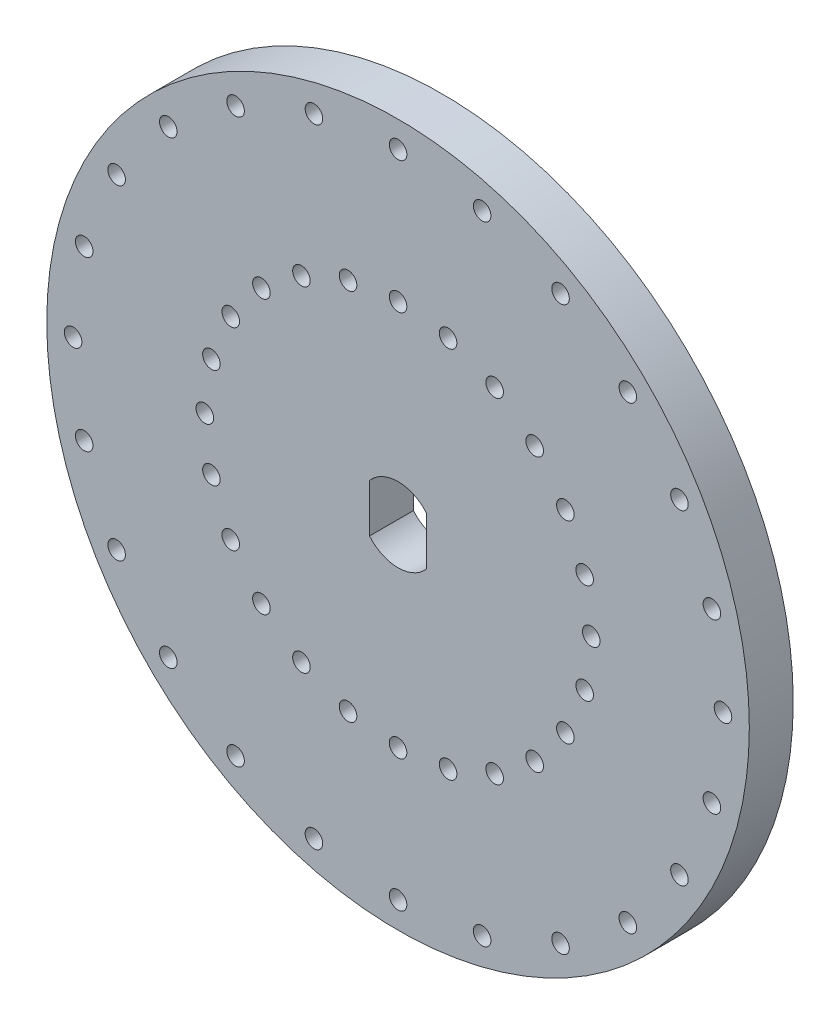
from build123d import *

# Parameters (mm, degrees)
SKETCH1_R           = 40
BOSS_EXTRUDE1_DEPTH = 5
SKETCH2_R           = 1
CUT_EXTRUDE1_DEPTH  = 5
CUT_EXTRUDE2_DEPTH  = 5


with BuildPart() as part:
    # Sketch1 → Boss-Extrude1 (new body)
    with BuildSketch(Plane.XY):
        Circle(SKETCH1_R)
    extrude(amount=BOSS_EXTRUDE1_DEPTH)

    # Sketch2 → Cut-Extrude1 (cut)
    with BuildSketch(Plane.XY):
        with Locations((0, 37)):
            Circle(SKETCH2_R)
        with Locations((0, 22)):
            Circle(SKETCH2_R)
        with Locations((5.694018992, 21.250368178)):
            Circle(SKETCH2_R)
        with Locations((9.576304669, 35.739255573)):
            Circle(SKETCH2_R)
        with Locations((11, 19.052558883)):
            Circle(SKETCH2_R)
        with Locations((18.5, 32.04293994)):
            Circle(SKETCH2_R)
        with Locations((15.556349186, 15.556349186)):
            Circle(SKETCH2_R)
        with Locations((26.162950904, 26.162950904)):
            Circle(SKETCH2_R)
        with Locations((19.052558883, 11)):
            Circle(SKETCH2_R)
        with Locations((32.04293994, 18.5)):
            Circle(SKETCH2_R)
        with Locations((21.250368178, 5.694018992)):
            Circle(SKETCH2_R)
        with Locations((35.739255573, 9.576304669)):
            Circle(SKETCH2_R)
        with Locations((22, 0)):
            Circle(SKETCH2_R)
        with Locations((37, 0)):
            Circle(SKETCH2_R)
        with Locations((21.250368178, -5.694018992)):
            Circle(SKETCH2_R)
        with Locations((35.739255573, -9.576304669)):
            Circle(SKETCH2_R)
        with Locations((19.052558883, -11)):
            Circle(SKETCH2_R)
        with Locations((32.04293994, -18.5)):
            Circle(SKETCH2_R)
        with Locations((15.556349186, -15.556349186)):
            Circle(SKETCH2_R)
        with Locations((26.162950904, -26.162950904)):
            Circle(SKETCH2_R)
        with Locations((11, -19.052558883)):
            Circle(SKETCH2_R)
        with Locations((18.5, -32.04293994)):
            Circle(SKETCH2_R)
        with Locations((5.694018992, -21.250368178)):
            Circle(SKETCH2_R)
        with Locations((9.576304669, -35.739255573)):
            Circle(SKETCH2_R)
        with Locations((0, -22)):
            Circle(SKETCH2_R)
        with Locations((0, -37)):
            Circle(SKETCH2_R)
        with Locations((-5.694018992, -21.250368178)):
            Circle(SKETCH2_R)
        with Locations((-9.576304669, -35.739255573)):
            Circle(SKETCH2_R)
        with Locations((-11, -19.052558883)):
            Circle(SKETCH2_R)
        with Locations((-18.5, -32.04293994)):
            Circle(SKETCH2_R)
        with Locations((-15.556349186, -15.556349186)):
            Circle(SKETCH2_R)
        with Locations((-26.162950904, -26.162950904)):
            Circle(SKETCH2_R)
        with Locations((-19.052558883, -11)):
            Circle(SKETCH2_R)
        with Locations((-32.04293994, -18.5)):
            Circle(SKETCH2_R)
        with Locations((-21.250368178, -5.694018992)):
            Circle(SKETCH2_R)
        with Locations((-35.739255573, -9.576304669)):
            Circle(SKETCH2_R)
        with Locations((-22, 0)):
            Circle(SKETCH2_R)
        with Locations((-37, 0)):
            Circle(SKETCH2_R)
        with Locations((-21.250368178, 5.694018992)):
            Circle(SKETCH2_R)
        with Locations((-35.739255573, 9.576304669)):
            Circle(SKETCH2_R)
        with Locations((-19.052558883, 11)):
            Circle(SKETCH2_R)
        with Locations((-32.04293994, 18.5)):
            Circle(SKETCH2_R)
        with Locations((-15.556349186, 15.556349186)):
            Circle(SKETCH2_R)
        with Locations((-26.162950904, 26.162950904)):
            Circle(SKETCH2_R)
        with Locations((-11, 19.052558883)):
            Circle(SKETCH2_R)
        with Locations((-18.5, 32.04293994)):
            Circle(SKETCH2_R)
        with Locations((-5.694018992, 21.250368178)):
            Circle(SKETCH2_R)
        with Locations((-9.576304669, 35.739255573)):
            Circle(SKETCH2_R)
    extrude(amount=CUT_EXTRUDE1_DEPTH, mode=Mode.SUBTRACT)

    # Sketch5 → Cut-Extrude2 (cut)
    with BuildSketch(Plane.XY):
        with BuildLine():
            Line((-3.25, 2.738612788), (-3.25, -2.738612788))
            ThreePointArc((-3.25, -2.738612788), (0, -4.25), (3.25, -2.738612788))
            Line((3.25, -2.738612788), (3.25, 2.738612788))
            ThreePointArc((3.25, 2.738612788), (0, 4.25), (-3.25, 2.738612788))
        make_face()
    extrude(amount=CUT_EXTRUDE2_DEPTH, mode=Mode.SUBTRACT)


solid = part.part
